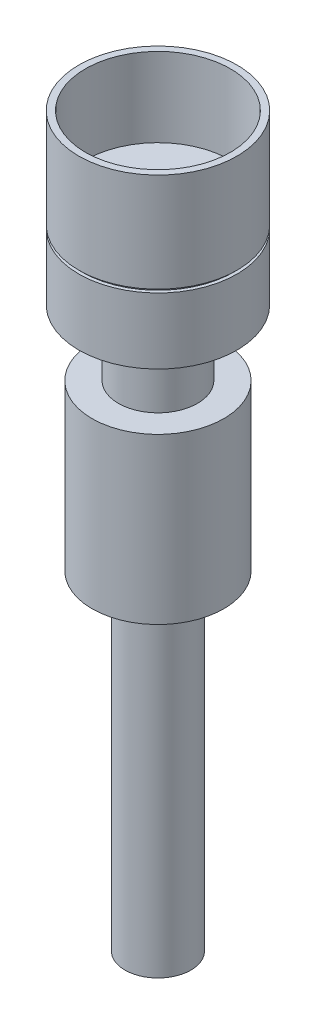
from build123d import *

# Parameters (mm, degrees)
SKETCH_1_R          = 10
EXTRUDE_1_DEPTH     = 25
SKETCH_2_R          = 5
EXTRUDE_2_DEPTH     = 50
SKETCH_3_R          = 6
EXTRUDE_3_DEPTH     = 10
SKETCH_4_R          = 12
EXTRUDE_4_DEPTH     = 10
EXTRUDE_START       = 0.5
SKETCH_5_R          = 12
EXTRUDE_5_DEPTH     = 15
SKETCH_6_R          = 11.5
EXTRUDE_6_DEPTH     = 1
SKETCH_7_R          = 11
CUT_EXTRUDE_1_DEPTH = 12


with BuildPart() as part:
    # 草图1 → 凸台-拉伸1 (new body)
    with BuildSketch(Plane(origin=(0, 0, 0), x_dir=(1, 0, 0), z_dir=(0, 1, 0))):
        Circle(SKETCH_1_R)
    extrude(amount=EXTRUDE_1_DEPTH)

    # 草图2 → 凸台-拉伸2 (add)
    with BuildSketch(Plane.XZ):
        Circle(SKETCH_2_R)
    extrude(amount=EXTRUDE_2_DEPTH)

    # 草图3 → 凸台-拉伸3 (add)
    with BuildSketch(Plane(origin=(0, 25, 0), x_dir=(1, 0, 0), z_dir=(0, 1, 0))):
        Circle(SKETCH_3_R)
    extrude(amount=EXTRUDE_3_DEPTH)

    # 草图4 → 凸台-拉伸4 (add)
    with BuildSketch(Plane(origin=(0, 35, 0), x_dir=(1, 0, 0), z_dir=(0, 1, 0))):
        Circle(SKETCH_4_R)
    extrude(amount=EXTRUDE_4_DEPTH)



with BuildPart() as body_2:
    # 草图5 → 凸台-拉伸5 (new body)
    with BuildSketch(Plane(origin=(0, 45, 0), x_dir=(1, 0, 0), z_dir=(0, 1, 0)).offset(EXTRUDE_START)):
        Circle(SKETCH_5_R)
    extrude(amount=EXTRUDE_5_DEPTH)


with BuildPart() as part_1:
    add(part.part)

    add(body_2.part)  # 凸台-拉伸6 merges body 2
    # 草图6 → 凸台-拉伸6 (add)
    with BuildSketch(Plane(origin=(0, 45, 0), x_dir=(1, 0, 0), z_dir=(0, 1, 0))):
        Circle(SKETCH_6_R)
    extrude(amount=EXTRUDE_6_DEPTH)

    # 草图7 → 切除-拉伸1 (cut)
    with BuildSketch(Plane(origin=(0, 60.5, 0), x_dir=(1, 0, 0), z_dir=(0, 1, 0))):
        Circle(SKETCH_7_R)
    extrude(amount=-CUT_EXTRUDE_1_DEPTH, mode=Mode.SUBTRACT)


solid = part_1.part
